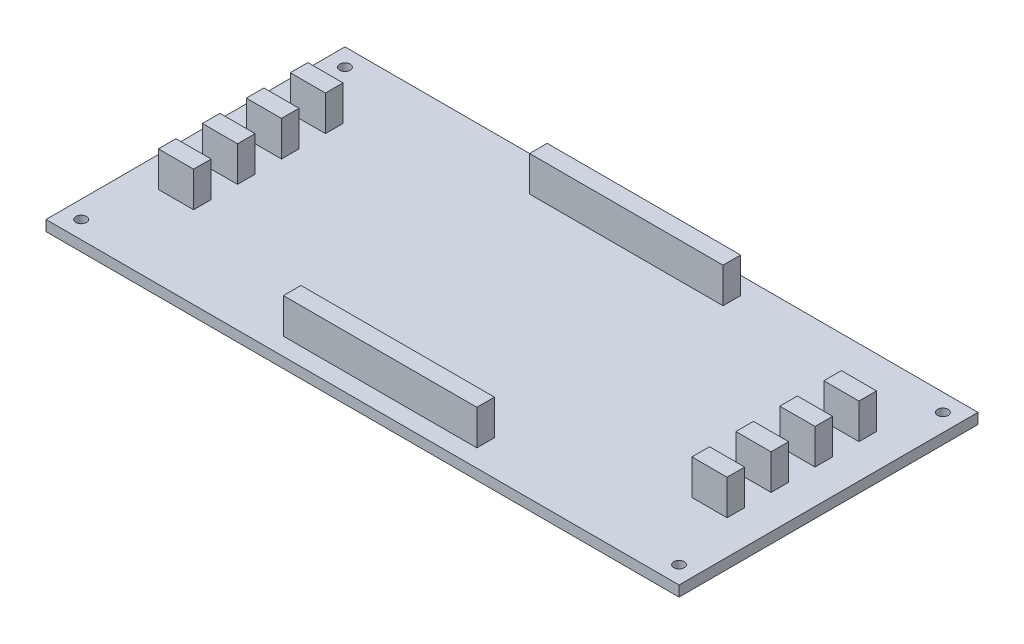
from build123d import *

# Parameters (mm, degrees)
ESQUISSE1_W      = 180
ESQUISSE1_H      = 85
ESQUISSE1_R      = 1.5
EXTRUSION1_DEPTH = 3
ESQUISSE2_W      = 55
ESQUISSE2_H      = 5
EXTRUSION2_DEPTH = 10
ESQUISSE4_W      = 10
ESQUISSE4_H      = 5
EXTRUSION4_DEPTH = 10


with BuildPart() as part:
    # Esquisse1 → Extrusion1 (new body)
    with BuildSketch(Plane(origin=(0, 0, 0), x_dir=(1, 0, 0), z_dir=(0, 1, 0))):
        with Locations((90, 42.5)):
            Rectangle(ESQUISSE1_W, ESQUISSE1_H)
        with Locations((5, 80)):
            Circle(ESQUISSE1_R, mode=Mode.SUBTRACT)
        with Locations((175, 80)):
            Circle(ESQUISSE1_R, mode=Mode.SUBTRACT)
        with Locations((175, 5)):
            Circle(ESQUISSE1_R, mode=Mode.SUBTRACT)
        with Locations((5, 5)):
            Circle(ESQUISSE1_R, mode=Mode.SUBTRACT)
    extrude(amount=EXTRUSION1_DEPTH)

    # Esquisse2 → Extrusion2 (add)
    with BuildSketch(Plane(origin=(0, 3, 0), x_dir=(1, 0, 0), z_dir=(0, 1, 0))):
        with Locations((90, 77.5)):
            Rectangle(ESQUISSE2_W, ESQUISSE2_H)
        with Locations((90, 7.5)):
            Rectangle(ESQUISSE2_W, ESQUISSE2_H)
    extrude(amount=EXTRUSION2_DEPTH)

    # Esquisse4 → Extrusion4 (add)
    with BuildSketch(Plane(origin=(0, 3, 0), x_dir=(1, 0, 0), z_dir=(0, 1, 0))):
        with Locations((165.295070297, 63.362289653)):
            Rectangle(ESQUISSE4_W, ESQUISSE4_H)
        with Locations((13.593769781, 63.362289653)):
            Rectangle(ESQUISSE4_W, ESQUISSE4_H)
        with Locations((13.593769781, 38.362289653)):
            Rectangle(ESQUISSE4_W, ESQUISSE4_H)
        with Locations((13.593769781, 25.862289653)):
            Rectangle(ESQUISSE4_W, ESQUISSE4_H)
        with Locations((13.593769781, 50.862289653)):
            Rectangle(ESQUISSE4_W, ESQUISSE4_H)
        with Locations((165.295070297, 38.362289653)):
            Rectangle(ESQUISSE4_W, ESQUISSE4_H)
        with Locations((165.295070297, 25.862289653)):
            Rectangle(ESQUISSE4_W, ESQUISSE4_H)
        with Locations((165.295070297, 50.862289653)):
            Rectangle(ESQUISSE4_W, ESQUISSE4_H)
    extrude(amount=EXTRUSION4_DEPTH)


solid = part.part
